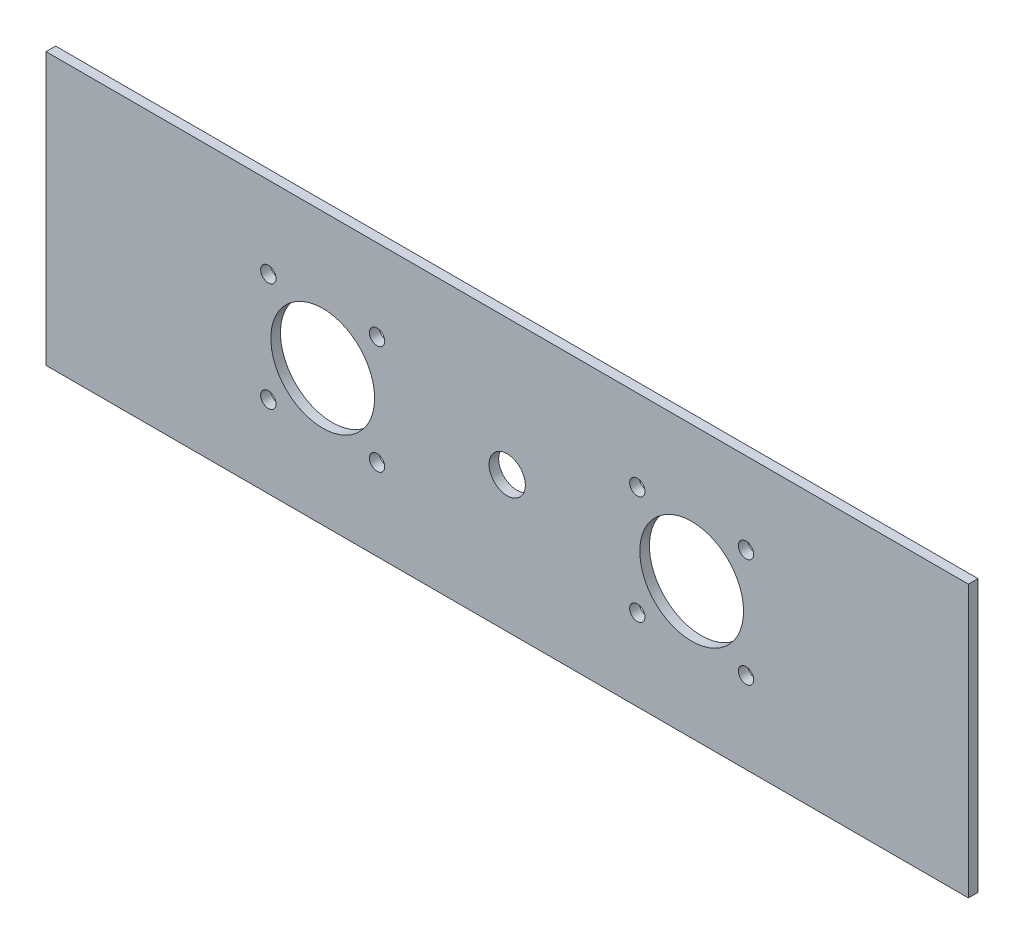
from build123d import *

# Parameters (mm, degrees)
SKETCH1_W           = 304.8
SKETCH1_H           = 89.8
SKETCH1_R           = 6
SKETCH1_R_2         = 2.54
SKETCH1_R_3         = 17.145
BOSS_EXTRUDE1_DEPTH = 3.175


with BuildPart() as part:
    # Sketch1 → Boss-Extrude1 (new body)
    with BuildSketch(Plane.XY):
        with Locations((152.4, 44.9)):
            Rectangle(SKETCH1_W, SKETCH1_H)
        with Locations((152.4, 44.9)):
            Circle(SKETCH1_R, mode=Mode.SUBTRACT)
        with Locations((109.401585406, 62.859439014)):
            Circle(SKETCH1_R_2, mode=Mode.SUBTRACT)
        with Locations((109.399439014, 26.938414594)):
            Circle(SKETCH1_R_2, mode=Mode.SUBTRACT)
        with Locations((73.478414594, 26.940560986)):
            Circle(SKETCH1_R_2, mode=Mode.SUBTRACT)
        with Locations((73.480560986, 62.861585406)):
            Circle(SKETCH1_R_2, mode=Mode.SUBTRACT)
        with Locations((91.44, 44.9)):
            Circle(SKETCH1_R_3, mode=Mode.SUBTRACT)
        with Locations((195.400560986, 62.861585406)):
            Circle(SKETCH1_R_2, mode=Mode.SUBTRACT)
        with Locations((231.321585406, 62.859439014)):
            Circle(SKETCH1_R_2, mode=Mode.SUBTRACT)
        with Locations((231.319439014, 26.938414594)):
            Circle(SKETCH1_R_2, mode=Mode.SUBTRACT)
        with Locations((195.398414594, 26.940560986)):
            Circle(SKETCH1_R_2, mode=Mode.SUBTRACT)
        with Locations((213.36, 44.9)):
            Circle(SKETCH1_R_3, mode=Mode.SUBTRACT)
    extrude(amount=BOSS_EXTRUDE1_DEPTH)


solid = part.part
